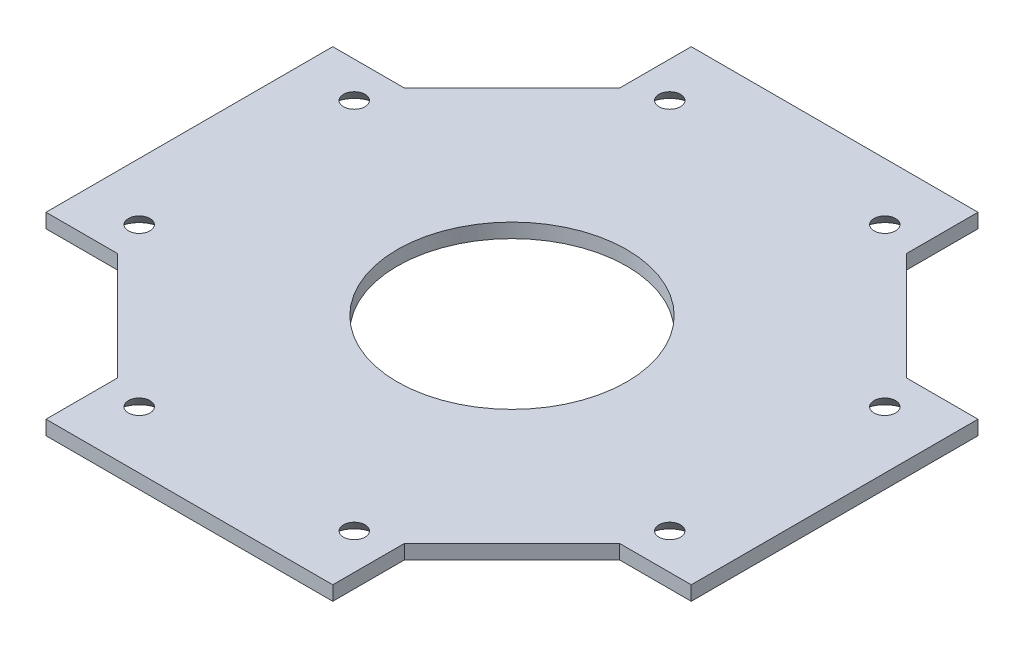
from build123d import *

# Parameters (mm, degrees)
RESSALTO_EXTRUS_O1_DEPTH        = 2
ESBO_O2_R                       = 1.5
CORTE_EXTRUS_O1_DEPTH           = 3
CORTE_EXTRUS_O1_TAPER           = -40
ESPELHAR3_COPY_1_SKETCH_R       = 1.5
ESPELHAR3_COPY_1_DEPTH          = 3
ESPELHAR3_COPY_1_TAPER          = -40
PADR_OCIRCULAR1_COUNT           = 2
PADR_OCIRCULAR1_ANGLE           = 90
PADR_OCIRCULAR1_COPY_1_SKETCH_R = 1.5
PADR_OCIRCULAR1_COPY_1_DEPTH    = 3
PADR_OCIRCULAR1_COPY_1_TAPER    = -40
PADR_OCIRCULAR1_COPY_2_SKETCH_R = 1.5
PADR_OCIRCULAR1_COPY_2_DEPTH    = 3
PADR_OCIRCULAR1_COPY_2_TAPER    = -40
PADR_OCIRCULAR1_COPY_3_SKETCH_R = 1.5
PADR_OCIRCULAR1_COPY_3_DEPTH    = 3
PADR_OCIRCULAR1_COPY_3_TAPER    = -40


with BuildPart() as part:
    # Esboço1 → Ressalto-extrusão1 (new body)
    with BuildSketch(Plane(origin=(0, 0, 0), x_dir=(1, 0, 0), z_dir=(0, 1, 0))):
        with BuildLine():
            Line((-20, 35), (-20, 45))
            Line((-20, 45), (0, 45))
            Line((0, 45), (0, 16))
            ThreePointArc((0, 16), (-16, 0), (0, -16))
            Line((0, -16), (0, -45))
            Line((0, -45), (-20, -45))
            Line((-20, -45), (-20, -35))
            Line((-20, -35), (-35, -20))
            Line((-35, -20), (-45, -20))
            Line((-45, -20), (-45, 20))
            Line((-45, 20), (-35, 20))
            Line((-35, 20), (-20, 35))
        make_face()
    ressalto_extrus_o1 = extrude(amount=RESSALTO_EXTRUS_O1_DEPTH)

    # Espelhar1: Ressalto-extrusão1 across plane
    add(ressalto_extrus_o1.mirror(Plane(origin=(0, 2, -16), x_dir=(0, 0, 1), z_dir=(-1, 0, 0))))

    # Esboço2 → Corte-extrusão1 (cut, through all)
    with BuildSketch(Plane(origin=(0, 2, 0), x_dir=(1, 0, 0), z_dir=(0, 1, 0))):
        with Locations((-15, 37)):
            Circle(ESBO_O2_R)
    corte_extrus_o1 = extrude(amount=-CORTE_EXTRUS_O1_DEPTH, taper=CORTE_EXTRUS_O1_TAPER, mode=Mode.SUBTRACT)

    # Espelhar2: Corte-extrusão1 across plane
    add(corte_extrus_o1.mirror(Plane(origin=(0, 0, 0), x_dir=(0, 0, 1), z_dir=(1, 0, 0))), mode=Mode.SUBTRACT)

    # Espelhar3: Corte-extrusão1 across plane
    add(corte_extrus_o1.mirror(Plane.XY), mode=Mode.SUBTRACT)

    # Espelhar3 copy 1 sketch → Espelhar3 copy 1 (cut, through all)
    with BuildSketch(Plane(origin=(0, 2, 0), x_dir=(-1, 0, 0), z_dir=(0, 1, 0))):
        with Locations((-15, 37)):
            Circle(ESPELHAR3_COPY_1_SKETCH_R)
    extrude(amount=-ESPELHAR3_COPY_1_DEPTH, taper=ESPELHAR3_COPY_1_TAPER, mode=Mode.SUBTRACT)

    # PadrãoCircular1: Corte-extrusão1 ×2 about axis
    padr_ocircular1_axis = Axis((0, 0, 0), (0, -1, 0))
    for i in range(1, PADR_OCIRCULAR1_COUNT):
        add(corte_extrus_o1.rotate(padr_ocircular1_axis, i * PADR_OCIRCULAR1_ANGLE / (PADR_OCIRCULAR1_COUNT - 1)), mode=Mode.SUBTRACT)

    # PadrãoCircular1 copy 1 sketch → PadrãoCircular1 copy 1 (cut, through all)
    with BuildSketch(Plane.ZX.offset(2)):
        with Locations((-15, -37)):
            Circle(PADR_OCIRCULAR1_COPY_1_SKETCH_R)
    extrude(amount=-PADR_OCIRCULAR1_COPY_1_DEPTH, taper=PADR_OCIRCULAR1_COPY_1_TAPER, mode=Mode.SUBTRACT)

    # PadrãoCircular1 copy 2 sketch → PadrãoCircular1 copy 2 (cut, through all)
    with BuildSketch(Plane(origin=(0, 2, 0), x_dir=(0, 0, -1), z_dir=(0, 1, 0))):
        with Locations((-15, 37)):
            Circle(PADR_OCIRCULAR1_COPY_2_SKETCH_R)
    extrude(amount=-PADR_OCIRCULAR1_COPY_2_DEPTH, taper=PADR_OCIRCULAR1_COPY_2_TAPER, mode=Mode.SUBTRACT)

    # PadrãoCircular1 copy 3 sketch → PadrãoCircular1 copy 3 (cut, through all)
    with BuildSketch(Plane(origin=(0, 2, 0), x_dir=(0, 0, -1), z_dir=(0, 1, 0))):
        with Locations((-15, -37)):
            Circle(PADR_OCIRCULAR1_COPY_3_SKETCH_R)
    extrude(amount=-PADR_OCIRCULAR1_COPY_3_DEPTH, taper=PADR_OCIRCULAR1_COPY_3_TAPER, mode=Mode.SUBTRACT)


solid = part.part
